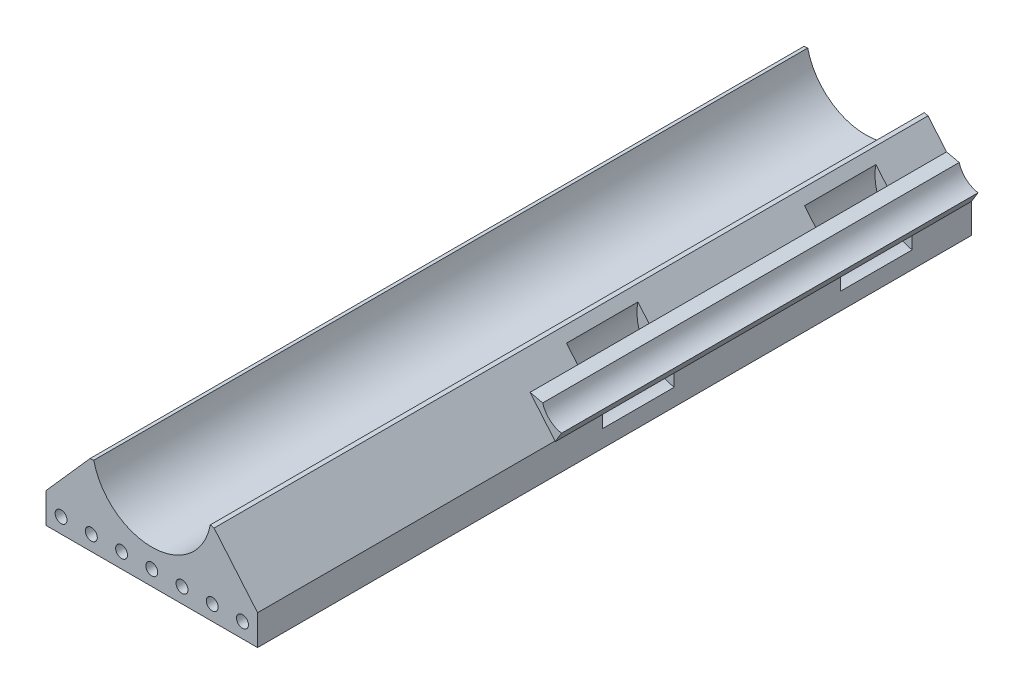
from build123d import *

# Parameters (mm, degrees)
SKETCH1_W           = 17.78
SKETCH1_H           = 2.54
SKETCH1_R           = 0.5
BOSS_EXTRUDE1_DEPTH = 60
CUT_EXTRUDE1_START  = 8
CUT_EXTRUDE1_DEPTH  = 3
CUT_EXTRUDE2_START  = 28
CUT_EXTRUDE2_DEPTH  = 3
BOSS_EXTRUDE2_DEPTH = 35


with BuildPart() as part:
    # Sketch1 → Boss-Extrude1 (new body)
    with BuildSketch(Plane.XY):
        with BuildLine():
            Line((-5.200349399, -1.156583023), (-4.875189675, -1.110191708))
            ThreePointArc((-4.875189675, -1.110191708), (0.094891357, -4.999099482), (4.913809284, -0.924379964))
            Line((4.913809284, -0.924379964), (5.23403324, -0.993083178))
            ThreePointArc((5.23403324, -0.993083178), (0.083466761, -5.326758063), (-5.200349399, -1.156583023))
        make_face()
        with BuildLine():
            Line((-5.200349399, -1.156583023), (-8.89, -5.327411957))
            Line((-8.89, -5.327411957), (-9e-09, -5.327411957))
            ThreePointArc((-9e-09, -5.327411957), (-3.33314596, -4.155894148), (-5.200349399, -1.156583023))
        make_face()
        with Locations((0, -6.597411957)):
            Rectangle(SKETCH1_W, SKETCH1_H)
        with Locations((7.62, -6.597411957)):
            Circle(SKETCH1_R, mode=Mode.SUBTRACT)
        with Locations((5.08, -6.597411957)):
            Circle(SKETCH1_R, mode=Mode.SUBTRACT)
        with Locations((2.54, -6.597411957)):
            Circle(SKETCH1_R, mode=Mode.SUBTRACT)
        with Locations((0, -6.597411957)):
            Circle(SKETCH1_R, mode=Mode.SUBTRACT)
        with Locations((-2.54, -6.597411957)):
            Circle(SKETCH1_R, mode=Mode.SUBTRACT)
        with Locations((-5.08, -6.597411957)):
            Circle(SKETCH1_R, mode=Mode.SUBTRACT)
        with Locations((-7.62, -6.597411957)):
            Circle(SKETCH1_R, mode=Mode.SUBTRACT)
        with BuildLine():
            ThreePointArc((5.23403324, -0.993083178), (3.397848946, -4.103162281), (-9e-09, -5.327411957))
            Line((-9e-09, -5.327411957), (8.89, -5.327411957))
            Line((8.89, -5.327411957), (5.23403324, -0.993083178))
        make_face()
    extrude(amount=BOSS_EXTRUDE1_DEPTH)

    # Sketch2 → Cut-Extrude1 (cut, symmetric)
    with BuildSketch(Plane.XY.offset(CUT_EXTRUDE1_START)):
        with BuildLine():
            ThreePointArc((6.790005825, -2.837765364), (7.456750164, -4.429353345), (8.89, -5.390339932))
            Line((8.89, -5.390339932), (8.89, -6.424592971))
            ThreePointArc((8.89, -6.424592971), (6.41429556, -4.694977723), (5.853473578, -1.727460228))
            Line((5.853473578, -1.727460228), (6.790005825, -2.837765364))
        make_face()
    extrude(amount=CUT_EXTRUDE1_DEPTH, both=True, mode=Mode.SUBTRACT)

    # Sketch2_3 → Cut-Extrude2 (cut, symmetric)
    with BuildSketch(Plane.XY.offset(CUT_EXTRUDE2_START)):
        with BuildLine():
            ThreePointArc((6.790005825, -2.837765364), (7.456750164, -4.429353345), (8.89, -5.390339932))
            Line((8.89, -5.390339932), (8.89, -6.424592971))
            ThreePointArc((8.89, -6.424592971), (6.41429556, -4.694977723), (5.853473578, -1.727460228))
            Line((5.853473578, -1.727460228), (6.790005825, -2.837765364))
        make_face()
    extrude(amount=CUT_EXTRUDE2_DEPTH, both=True, mode=Mode.SUBTRACT)

    # Sketch2_4 → Boss-Extrude2 (add)
    with BuildSketch(Plane.XY):
        with BuildLine():
            Line((7.852011126, -3.078294754), (6.790005825, -2.837765364))
            ThreePointArc((6.790005825, -2.837765364), (7.456750164, -4.429353345), (8.89, -5.390339932))
            Line((8.89, -5.390339932), (9.432365549, -4.494075888))
            ThreePointArc((9.432365549, -4.494075888), (8.438966293, -4.01303031), (7.852011126, -3.078294754))
        make_face()
    extrude(amount=BOSS_EXTRUDE2_DEPTH)


solid = part.part
